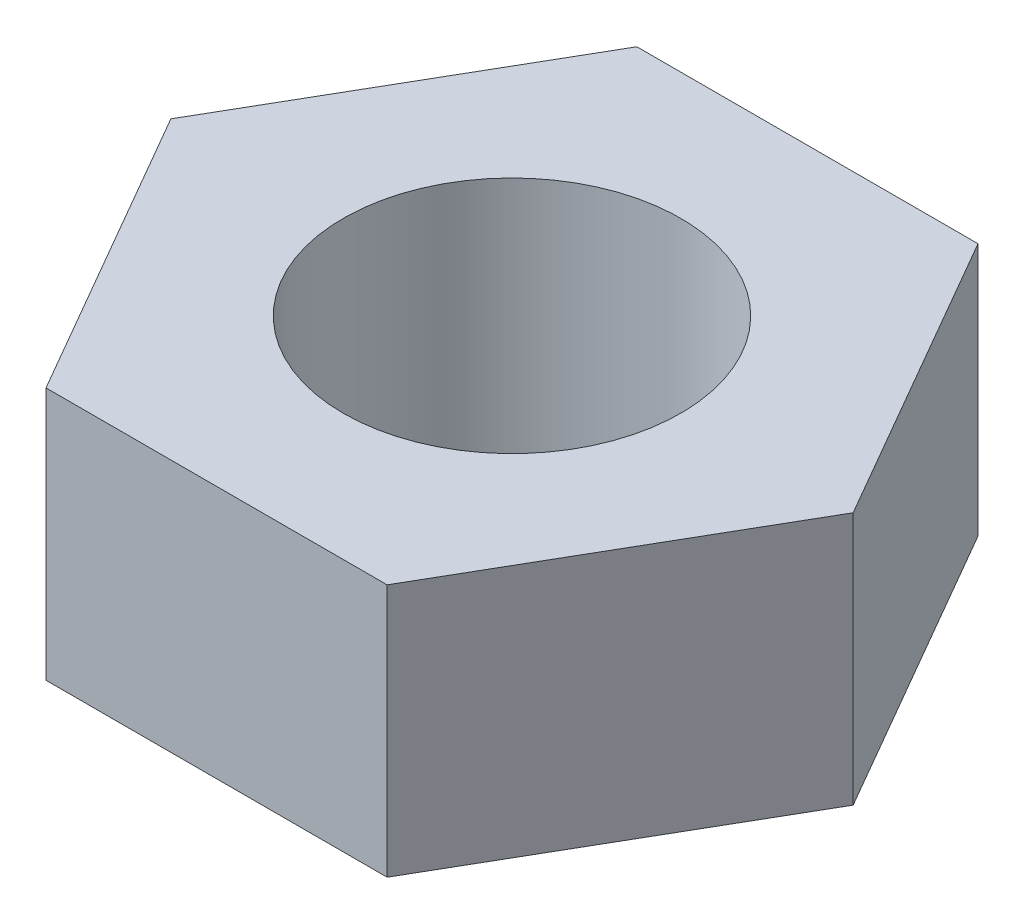
from build123d import *

# Parameters (mm, degrees)
SKETCH_1_R      = 2
EXTRUDE_1_DEPTH = 3


with BuildPart() as part:
    # 草图1 → 凸台-拉伸1 (new body)
    with BuildSketch(Plane(origin=(0, 0, 0), x_dir=(1, 0, 0), z_dir=(0, 1, 0))):
        Polygon((4.041451884, 0), (2.020725942, 3.5), (-2.020725942, 3.5), (-4.041451884, 0), (-2.020725942, -3.5), (2.020725942, -3.5), align=None)
        Circle(SKETCH_1_R, mode=Mode.SUBTRACT)
    extrude(amount=EXTRUDE_1_DEPTH)


solid = part.part
